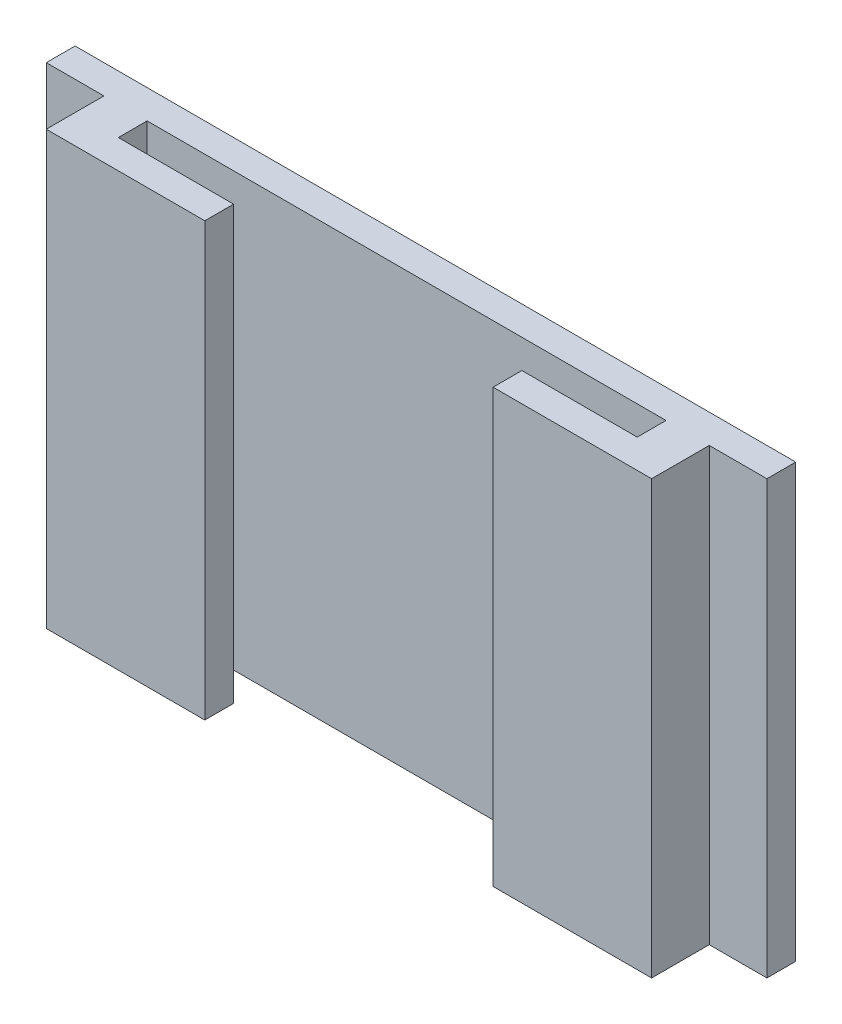
from build123d import *

# Parameters (mm, degrees)
SKETCH1_W               = 25
SKETCH1_H               = 15
BOSS_EXTRUDE1_DEPTH     = 1
SKETCH2_W               = 21
SKETCH2_H               = 15
BOSS_EXTRUDE2_DEPTH     = 3
CUT_EXTRUDE1_DEPTH      = 8.5
CUT_EXTRUDE1_DEPTH_BACK = 8.5


with BuildPart() as part:
    # Sketch1 → Boss-Extrude1 (new body)
    with BuildSketch(Plane.XY):
        Rectangle(SKETCH1_W, SKETCH1_H)
    extrude(amount=BOSS_EXTRUDE1_DEPTH)

    # Sketch2 → Boss-Extrude2 (add)
    with BuildSketch(Plane.XY):
        Rectangle(SKETCH2_W, SKETCH2_H)
    extrude(amount=BOSS_EXTRUDE2_DEPTH)

    # Sketch3 → Cut-Extrude1 (cut, two sides)
    with BuildSketch(Plane(origin=(0, 0, 0), x_dir=(1, 0, 0), z_dir=(0, 1, 0))) as cut_extrude1_sk:
        Polygon((-9, -2), (-5, -2), (-5, -3), (5, -3), (5, -2), (9, -2), (9, -1), (-9, -1), align=None)
    extrude(amount=CUT_EXTRUDE1_DEPTH, mode=Mode.SUBTRACT)
    extrude(cut_extrude1_sk.sketch, amount=-CUT_EXTRUDE1_DEPTH_BACK, mode=Mode.SUBTRACT)


solid = part.part
